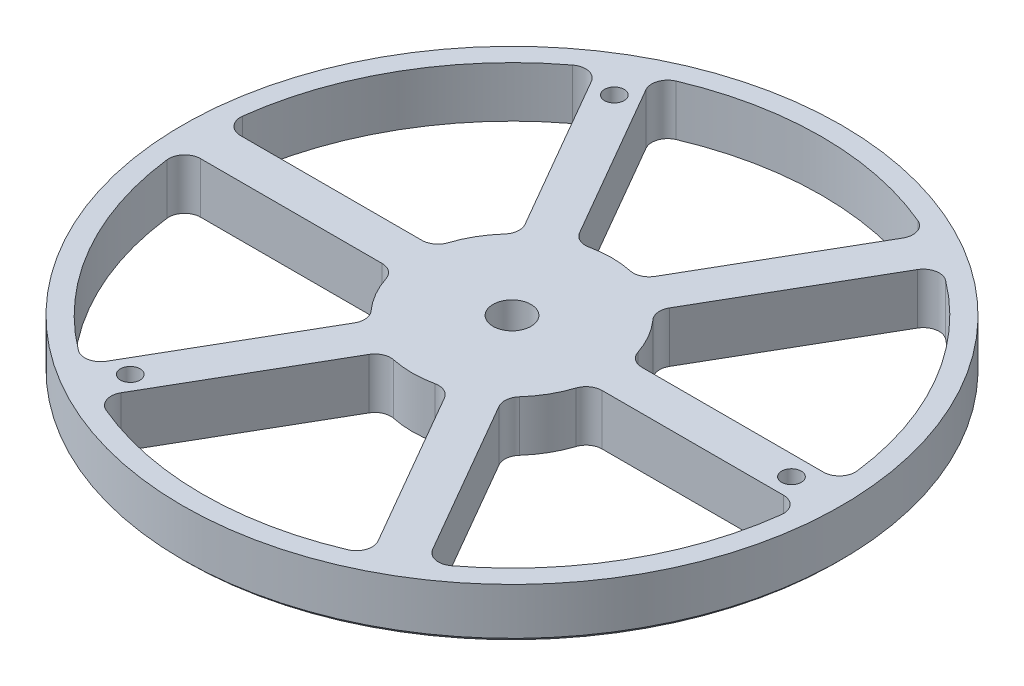
from build123d import *

# Parameters (mm, degrees)
SKETCH2_W                    = 82.55
SKETCH2_H                    = 12.7
F_10_0_1935_DIAMETER_HOLE1_D = 4.9149
CIRPATTERN3_COUNT            = 3
CUT_EXTRUDE1_DEPTH           = 13.7
FILLET1_R                    = 4
CIRPATTERN4_COUNT            = 6
FILLET1_OF_CIRPATTERN4_R     = 4
CHAMFER2_SIZE                = 1
F_3_8_0_375_DIAMETER_HOLE1_D = 9.525


with BuildPart() as part:
    # Sketch2 → Revolve1 (revolve)
    with BuildSketch(Plane(origin=(0, 0, 0), x_dir=(0, 0, -1), z_dir=(1, 0, 0))):
        with Locations((-41.275, 6.35)):
            Rectangle(SKETCH2_W, SKETCH2_H)
    revolve(axis=Axis((0, -0.635, 0), (0, 1, 0)))

    # #10 (0.1935) Diameter Hole1 (through all)
    with Locations(Plane(origin=(0, 12.7, 0), x_dir=(1, 0, 0), z_dir=(0, 1, 0))):
        with Locations((-35, 60.621778)):
            f_10_0_1935_diameter_hole1 = Hole(F_10_0_1935_DIAMETER_HOLE1_D / 2)

    # CirPattern3: #10 (0.1935) Diameter Hole1 ×3 about axis
    cirpattern3_axis = Axis((0, 0, 0), (0, 1, 0))
    for i in range(1, CIRPATTERN3_COUNT):
        add(f_10_0_1935_diameter_hole1.rotate(cirpattern3_axis, i * 360 / CIRPATTERN3_COUNT), mode=Mode.SUBTRACT)

    # Sketch8 → Cut-Extrude1 (cut, through all)
    with BuildSketch(Plane(origin=(0, 12.7, 0), x_dir=(1, 0, 0), z_dir=(0, 1, 0))):
        with BuildLine():
            Line((-7.917322, 23.713203), (-34.364196, 69.520533))
            ThreePointArc((-34.364196, 69.520533), (0, 77.55), (34.364196, 69.520533))
            Line((34.364196, 69.520533), (7.917322, 23.713203))
            ThreePointArc((7.917322, 23.713203), (0, 25), (-7.917322, 23.713203))
        make_face()
    cut_extrude1 = extrude(amount=-CUT_EXTRUDE1_DEPTH, mode=Mode.SUBTRACT)

    # Fillet1
    fillet1_edges = [part.edges().sort_by_distance(p)[0] for p in [
        (7.917322, 6.35, -23.713203),
        (-7.917322, 6.35, -23.713203),
        (-34.364196, 6.35, -69.520533),
        (34.364196, 6.35, -69.520533),
    ]]
    fillet(fillet1_edges, radius=FILLET1_R)

    # CirPattern4: Cut-Extrude1 ×6 about axis
    cirpattern4_axis = Axis((0, 0, 0), (0, 1, 0))
    for i in range(1, CIRPATTERN4_COUNT):
        add(cut_extrude1.rotate(cirpattern4_axis, i * 360 / CIRPATTERN4_COUNT), mode=Mode.SUBTRACT)

    # Fillet1 of CirPattern4
    fillet1_of_cirpattern4_edges = [part.edges().sort_by_distance(p)[0] for p in [
        (-16.577576, 6.35, -18.713203),
        (-24.494897, 6.35, -5),
        (-77.388646, 6.35, -5),
        (-43.02445, 6.35, -64.520533),
        (-24.494897, 6.35, 5),
        (-16.577576, 6.35, 18.713203),
        (-43.02445, 6.35, 64.520533),
        (-77.388646, 6.35, 5),
        (-7.917322, 6.35, 23.713203),
        (7.917322, 6.35, 23.713203),
        (34.364196, 6.35, 69.520533),
        (-34.364196, 6.35, 69.520533),
        (16.577576, 6.35, 18.713203),
        (24.494897, 6.35, 5),
        (77.388646, 6.35, 5),
        (43.02445, 6.35, 64.520533),
        (24.494897, 6.35, -5),
        (16.577576, 6.35, -18.713203),
        (43.02445, 6.35, -64.520533),
        (77.388646, 6.35, -5),
    ]]
    fillet(fillet1_of_cirpattern4_edges, radius=FILLET1_OF_CIRPATTERN4_R)

    # Chamfer2
    chamfer2_edges = [part.edges().sort_by_distance(p)[0] for p in [
        (0, 0, -82.55),
    ]]
    chamfer(chamfer2_edges, length=CHAMFER2_SIZE)

    # 3/8 (0.375) Diameter Hole1 (through all)
    with Locations(Plane(origin=(0, 0, 0), x_dir=(-1, 0, 0), z_dir=(0, -1, 0))):
        with Locations((0, 0)):
            Hole(F_3_8_0_375_DIAMETER_HOLE1_D / 2)


solid = part.part
